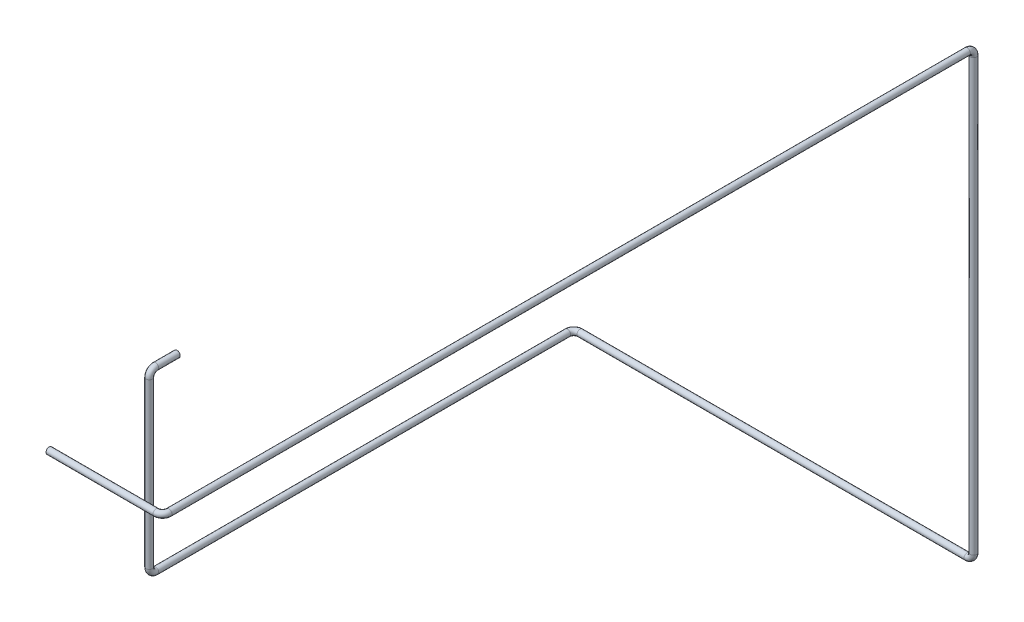
from build123d import *

# Parameters (mm, degrees)
SWEEP_THIN1_PROFILE_R   = 15
SWEEP_THIN1_PROFILE_R_2 = 14


with BuildPart() as part:
    # Sweep-Thin1: sweep along a curve in space
    with BuildLine() as sweep_thin1_path:
        Line((-29691.51617229, -14997.013633934, 42998.390196057), (-29185.300028665, -14997.013633934, 42998.390196057))
        ThreePointArc((-29155.300028665, -14997.013633934, 42968.390196057), (-29164.08682523, -14997.013633934, 42989.603399492), (-29185.300028665, -14997.013633934, 42998.390196057))
        Line((-29155.300028665, -14997.013633934, 42968.390196057), (-29155.300028665, -14997.013633934, 39192.641204298))
        ThreePointArc((-29155.300028665, -15027.013633934, 39162.641204298), (-29155.300028665, -15005.800430499, 39171.428000862), (-29155.300028665, -14997.013633934, 39192.641204298))
        Line((-29155.300028665, -15027.013633934, 39162.641204298), (-29155.300028665, -17064.666074338, 39162.641204298))
        ThreePointArc((-29185.300028665, -17094.666074338, 39162.641204298), (-29164.08682523, -17085.879277774, 39162.641204298), (-29155.300028665, -17064.666074338, 39162.641204298))
        Line((-29185.300028665, -17094.666074338, 39162.641204298), (-31016.033515707, -17094.666074338, 39162.641204298))
        ThreePointArc((-31046.033515707, -17094.666074338, 39192.641204298), (-31037.246719143, -17094.666074338, 39171.428000862), (-31016.033515707, -17094.666074338, 39162.641204298))
        Line((-31046.033515707, -17094.666074338, 39192.641204298), (-31046.033515707, -17094.666074338, 41140.636826071))
        ThreePointArc((-31046.033515707, -17064.666074338, 41170.636826071), (-31046.033515707, -17085.879277774, 41161.850029506), (-31046.033515707, -17094.666074338, 41140.636826071))
        Line((-31046.033515707, -17064.666074338, 41170.636826071), (-31046.033515707, -16287.859506292, 41170.636826071))
        ThreePointArc((-31046.033515707, -16257.859506292, 41140.636826071), (-31046.033515707, -16266.646302856, 41161.850029506), (-31046.033515707, -16287.859506292, 41170.636826071))
        Line((-31046.033515707, -16257.859506292, 41140.636826071), (-31046.033515707, -16257.859506292, 41039.236712281))
    # Sweep-Thin1 profile (on start of the path) → Sweep-Thin1 (sweep)
    with BuildSketch(Plane(origin=(-29691.51617229, -14997.013633934, 42998.390196057), x_dir=(0, 0, 1), z_dir=(1, 0, 0))):
        Circle(SWEEP_THIN1_PROFILE_R)
        Circle(SWEEP_THIN1_PROFILE_R_2, mode=Mode.SUBTRACT)
    sweep(path=sweep_thin1_path.line)


solid = part.part
